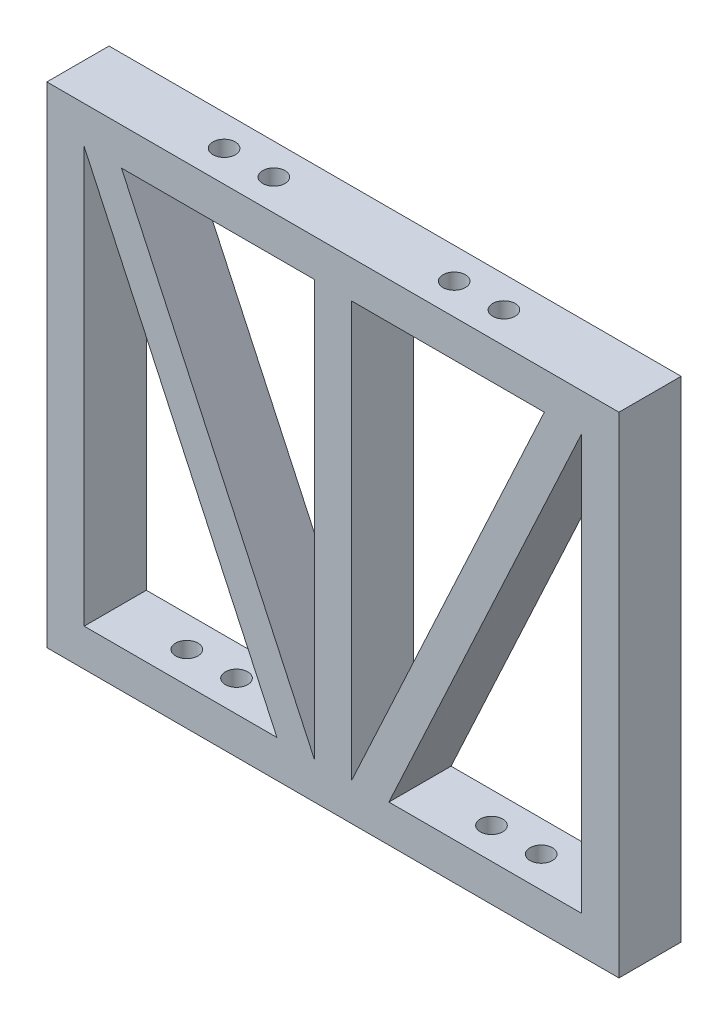
from build123d import *

# Parameters (mm, degrees)
SKETCH1_W           = 58.42
SKETCH1_H           = 50.038
BOSS_EXTRUDE1_DEPTH = 6.35
SKETCH2_R           = 1.143
CUT_EXTRUDE1_DEPTH  = 3.81
SKETCH3_R           = 1.143
CUT_EXTRUDE2_DEPTH  = 3.81


with BuildPart() as part:
    # Sketch1 → Boss-Extrude1 (new body)
    with BuildSketch(Plane.XY):
        with Locations((0, 25.019)):
            Rectangle(SKETCH1_W, SKETCH1_H)
        Polygon((-25.4, 46.228), (-25.4, 3.81), (-5.715, 3.81), align=None, mode=Mode.SUBTRACT)
        Polygon((1.905, 46.228), (1.905, 3.81), (21.59, 46.228), align=None, mode=Mode.SUBTRACT)
        Polygon((-21.59, 46.228), (-1.905, 3.81), (-1.905, 46.228), align=None, mode=Mode.SUBTRACT)
        Polygon((5.715, 3.81), (25.4, 46.228), (25.4, 3.81), align=None, mode=Mode.SUBTRACT)
    extrude(amount=BOSS_EXTRUDE1_DEPTH)

    # Sketch2 → Cut-Extrude1 (cut)
    with BuildSketch(Plane(origin=(0, 0, 0), x_dir=(1, 0, 0), z_dir=(0, 1, 0))):
        with Locations((-18.0975, -3.175)):
            Circle(SKETCH2_R)
        with Locations((-13.0175, -3.175)):
            Circle(SKETCH2_R)
        with Locations((18.0975, -3.175)):
            Circle(SKETCH2_R)
        with Locations((13.0175, -3.175)):
            Circle(SKETCH2_R)
    extrude(amount=CUT_EXTRUDE1_DEPTH, mode=Mode.SUBTRACT)

    # Sketch3 → Cut-Extrude2 (cut)
    with BuildSketch(Plane(origin=(0, 50.038, 0), x_dir=(1, 0, 0), z_dir=(0, 1, 0))):
        with Locations((-14.2875, -3.175)):
            Circle(SKETCH3_R)
        with Locations((-9.2075, -3.175)):
            Circle(SKETCH3_R)
        with Locations((9.2075, -3.175)):
            Circle(SKETCH3_R)
        with Locations((14.2875, -3.175)):
            Circle(SKETCH3_R)
    extrude(amount=-CUT_EXTRUDE2_DEPTH, mode=Mode.SUBTRACT)


solid = part.part
